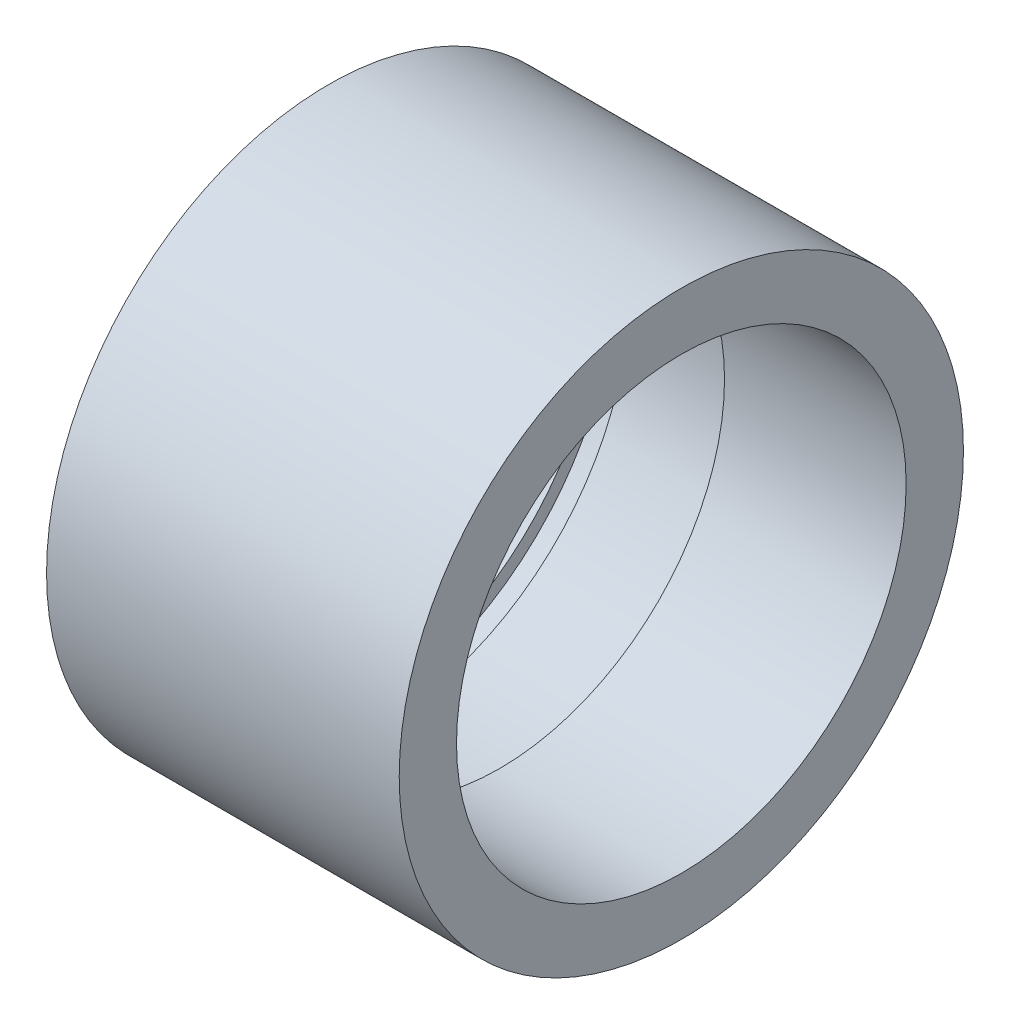
from build123d import *


with BuildPart() as part:
    # Эскиз1 → Повернуть1 (revolve)
    with BuildSketch(Plane(origin=(0, 0, 0), x_dir=(1, 0, 0), z_dir=(0, 1, 0))):
        Polygon((-1.5, 14), (0, 14), (0, 14.75), (1.5, 14.75), (1.5, 14), (8.2, 14), (8.2, 12.75), (18.5, 12.75), (18.5, 16), (-1.5, 16), align=None)
    revolve(axis=Axis((-1000, 0, 0), (1, 0, 0)))


solid = part.part
